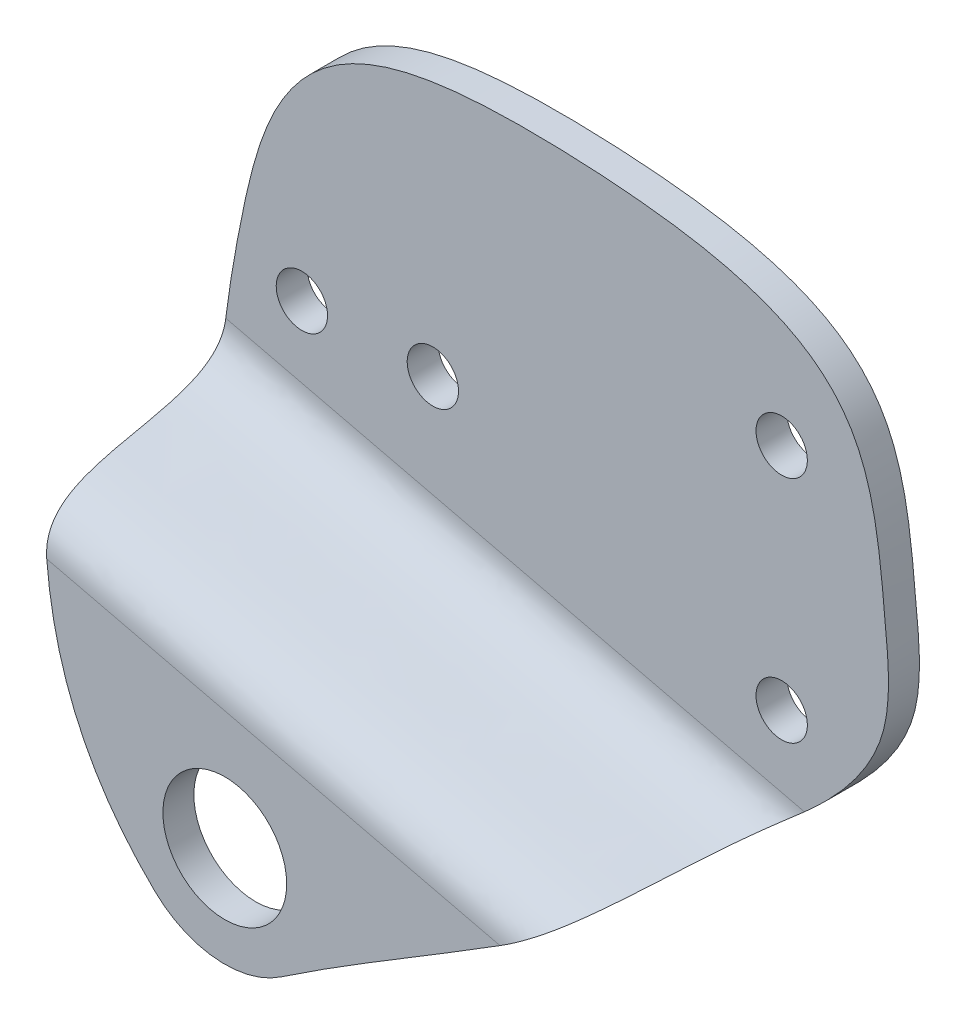
from build123d import *

# Parameters (mm, degrees)
MAIN_FEATURES_SKETCH_R   = 6
MAIN_FEATURES_SKETCH_R_2 = 2.4892
BOSS_EXTRUDE1_DEPTH      = 20
CUT_EXTRUDE1_DEPTH       = 63.701894918
CUT_EXTRUDE1_DEPTH_BACK  = 17.04931838


with BuildPart() as part:
    # main_features_sketch → Boss-Extrude1 (new body)
    with BuildSketch(Plane.XY):
        with BuildLine():
            ThreePointArc((-6.758273113, -14.327677037), (-0.830819524, -17.014537504), (5.466795464, -15.373205519))
            add(Edge.make_bspline(
                [(-6.758273113, -14.327677037), (-19.815407904, -1.771083652), (-17.868094073, 18.374574848), (-11.559395694, 47.113885006), (0.771302016, 51.653694953), (45.134222968, 49.048434389), (46.011316289, 37.291135993), (48.846230439, 7.873087579), (21.98254038, -4.189519042), (5.466795464, -15.373205519)],
                knots=[0, 0, 0, 0, 0.179468051, 0.221834172, 0.401235983, 0.455769682, 0.712637465, 0.770271344, 1, 1, 1, 1], degree=3))
        make_face()
        with Locations((0, -7.3)):
            Circle(MAIN_FEATURES_SKETCH_R, mode=Mode.SUBTRACT)
        with Locations((3.175, 25.4)):
            Circle(MAIN_FEATURES_SKETCH_R_2, mode=Mode.SUBTRACT)
        with Locations((37, 36.5125)):
            Circle(MAIN_FEATURES_SKETCH_R_2, mode=Mode.SUBTRACT)
        with Locations((37, 14.2875)):
            Circle(MAIN_FEATURES_SKETCH_R_2, mode=Mode.SUBTRACT)
        with Locations((-9.525, 25.4)):
            Circle(MAIN_FEATURES_SKETCH_R_2, mode=Mode.SUBTRACT)
    extrude(amount=BOSS_EXTRUDE1_DEPTH)

    # Sketch2 → Cut-Extrude1 (cut, two sides)
    with BuildSketch(Plane(origin=(-12.676008996, 1.492836838, 0), x_dir=(0, 0, -1), z_dir=(0.972640537, -0.232315271, 0))) as cut_extrude1_sk:
        with BuildLine():
            Line((-3, 56.346373374), (-3, 17.267886161))
            add(Edge.make_bspline(
                [(-3, 17.267886161), (-3, 9.58747876), (-20, 13.827131116), (-20, 5.61289325)],
                knots=[0, 0, 0, 0, 1, 1, 1, 1], degree=3))
            Line((-20, 5.61289325), (-20, 56.346373374))
            Line((-20, 56.346373374), (-3, 56.346373374))
        make_face()
        with BuildLine():
            add(Edge.make_bspline(
                [(0, 15.460949335), (0, 9.016747051), (-17, 7.038917007), (-17, 4.540018839)],
                knots=[0, 0, 0, 0, 1, 1, 1, 1], degree=3))
            Line((-17, 4.540018839), (-17, -15.357439085))
            Line((-17, -15.357439085), (0, -15.357439085))
            Line((0, -15.357439085), (0, 15.460949335))
        make_face()
    extrude(amount=CUT_EXTRUDE1_DEPTH, mode=Mode.SUBTRACT)
    extrude(cut_extrude1_sk.sketch, amount=-CUT_EXTRUDE1_DEPTH_BACK, mode=Mode.SUBTRACT)


solid = part.part
